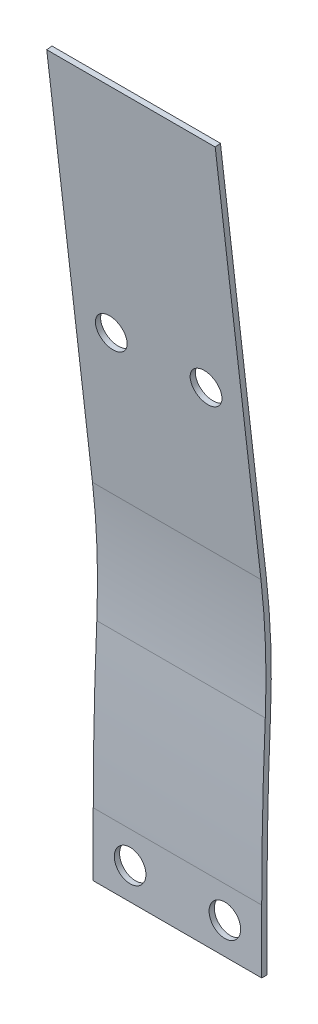
from build123d import *

# Parameters (mm, degrees)
SKETCH1_W           = 16
SKETCH1_H           = 6
SKETCH1_R           = 1.5
BOSS_EXTRUDE1_DEPTH = 0.5
BOSS_EXTRUDE2_DEPTH = 16
SKETCH3_R           = 1.5
CUT_EXTRUDE1_DEPTH  = 8.659646886
SKETCH4_W           = 16
SKETCH4_H           = 8
BOSS_EXTRUDE3_DEPTH = 0.5


with BuildPart() as part:
    # Sketch1 → Boss-Extrude1 (new body)
    with BuildSketch(Plane.XY):
        Rectangle(SKETCH1_W, SKETCH1_H)
        with Locations((-4.5, 0)):
            Circle(SKETCH1_R, mode=Mode.SUBTRACT)
        with Locations((4.5, 0)):
            Circle(SKETCH1_R, mode=Mode.SUBTRACT)
    extrude(amount=BOSS_EXTRUDE1_DEPTH)

    # Sketch2 → Boss-Extrude2 (add)
    with BuildSketch(Plane.ZY.offset(8)):
        with BuildLine():
            ThreePointArc((0.163996883, 18.220231427), (0.415988989, 10.611969896), (0.5, 3))
            Line((0.5, 3), (0, 3))
            ThreePointArc((0, 3), (-0.083889217, 10.600934542), (-0.335516001, 18.198166096))
            ThreePointArc((-0.335516001, 18.198166096), (-0.36155667, 24.039453598), (0.075644223, 29.864414815))
            Line((0.075644223, 29.864414815), (1.666879953, 43.688343289))
            Line((1.666879953, 43.688343289), (1.914976685, 45.843694255))
            Line((1.914976685, 45.843694255), (3.506212415, 59.667622728))
            Line((3.506212415, 59.667622728), (4.002932547, 59.610446591))
            Line((4.002932547, 59.610446591), (0.572364355, 29.807238679))
            ThreePointArc((0.572364355, 29.807238679), (0.138133092, 24.021842748), (0.163996883, 18.220231427))
        make_face()
    extrude(amount=-BOSS_EXTRUDE2_DEPTH)

    # Sketch3 → Cut-Extrude1 (cut, through all)
    with BuildSketch(Plane(origin=(0, 0.381926952, -3.318006735), x_dir=(-1, 0, 0), z_dir=(0, 0.114352273, -0.993440264))):
        with Locations((-4.5, 44.67716222)):
            Circle(SKETCH3_R)
        with Locations((4.5, 44.67716222)):
            Circle(SKETCH3_R)
    extrude(amount=-CUT_EXTRUDE1_DEPTH, mode=Mode.SUBTRACT)

    # Sketch4 → Boss-Extrude3 (add)
    with BuildSketch(Plane(origin=(0, 0.381926952, -3.318006735), x_dir=(-1, 0, 0), z_dir=(0, 0.114352273, -0.993440264))):
        with Locations((0, 63.67716222)):
            Rectangle(SKETCH4_W, SKETCH4_H)
    extrude(amount=-BOSS_EXTRUDE3_DEPTH)


solid = part.part
